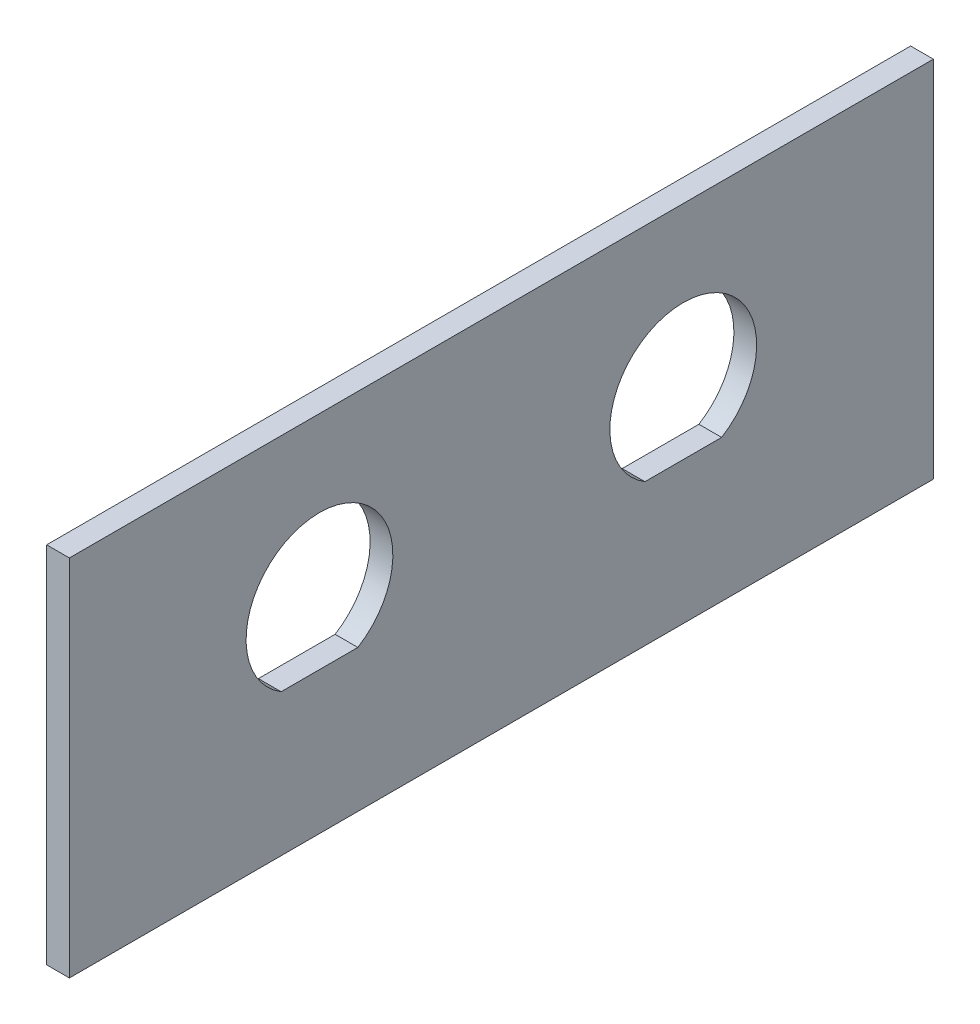
from build123d import *

# Parameters (mm, degrees)
SKETCH1_W           = 203.2
SKETCH1_H           = 120.65
BOSS_EXTRUDE1_DEPTH = 50.8
SKETCH2_W           = 196.85
SKETCH2_H           = 114.3
CUT_EXTRUDE1_DEPTH  = 51.8
SKETCH4_W           = 203.2
SKETCH4_H           = 120.65
SKETCH4_W_2         = 196.85
SKETCH4_H_2         = 114.3
BOSS_EXTRUDE2_DEPTH = 6.35
CUT_EXTRUDE5_DEPTH  = 121.65
CUT_EXTRUDE6_REACH  = 205.2
CUT_EXTRUDE7_REACH  = 205.2
SKETCH13_R          = 12.55395
SKETCH14_W          = 200.025
SKETCH14_H          = 120.65
CUT_EXTRUDE8_DEPTH  = 51.8


with BuildPart() as part:
    # Sketch1 → Boss-Extrude1 (new body)
    with BuildSketch(Plane(origin=(0, 0, 0), x_dir=(1, 0, 0), z_dir=(0, 1, 0))):
        Rectangle(SKETCH1_W, SKETCH1_H)
    extrude(amount=BOSS_EXTRUDE1_DEPTH)

    # Sketch2 → Cut-Extrude1 (cut, through all)
    with BuildSketch(Plane(origin=(0, 50.8, 0), x_dir=(1, 0, 0), z_dir=(0, 1, 0))):
        Rectangle(SKETCH2_W, SKETCH2_H)
    extrude(amount=-CUT_EXTRUDE1_DEPTH, mode=Mode.SUBTRACT)

    # Sketch4 → Boss-Extrude2 (add)
    with BuildSketch(Plane(origin=(0, 50.8, 0), x_dir=(1, 0, 0), z_dir=(0, 1, 0))):
        Rectangle(SKETCH4_W, SKETCH4_H)
        Rectangle(SKETCH4_W_2, SKETCH4_H_2, mode=Mode.SUBTRACT)
    extrude(amount=-BOSS_EXTRUDE2_DEPTH)

    # Sketch10 → Cut-Extrude5 (cut, through all)
    with BuildSketch(Plane.XY.offset(60.325)):
        with BuildLine():
            ThreePointArc((-65.9511, 22.225), (-81.206975571, 31.167602912), (-81.556705839, 13.4874))
            Line((-81.556705839, 13.4874), (-70.843294161, 13.4874))
            ThreePointArc((-70.843294161, 13.4874), (-67.257397088, 17.218024429), (-65.9511, 22.225))
        make_face()
        with BuildLine():
            ThreePointArc((-15.1511, 22.225), (-30.406975571, 31.167602912), (-30.756705839, 13.4874))
            Line((-30.756705839, 13.4874), (-20.043294161, 13.4874))
            ThreePointArc((-20.043294161, 13.4874), (-16.457397088, 17.218024429), (-15.1511, 22.225))
        make_face()
        with BuildLine():
            ThreePointArc((35.6489, 22.225), (20.393024429, 31.167602912), (20.043294161, 13.4874))
            Line((20.043294161, 13.4874), (30.756705839, 13.4874))
            ThreePointArc((30.756705839, 13.4874), (34.342602912, 17.218024429), (35.6489, 22.225))
        make_face()
        with BuildLine():
            Line((70.843294161, 13.4874), (81.556705839, 13.4874))
            ThreePointArc((81.556705839, 13.4874), (85.142602912, 17.218024429), (86.4489, 22.225))
            ThreePointArc((86.4489, 22.225), (71.193024429, 31.167602912), (70.843294161, 13.4874))
        make_face()
    extrude(amount=-CUT_EXTRUDE5_DEPTH, mode=Mode.SUBTRACT)

    # Sketch12 → Cut-Extrude6 (cut, up to next)
    with BuildSketch(Plane(origin=(101.6, 0, 0), x_dir=(0, 0, -1), z_dir=(1, 0, 0)), mode=Mode.PRIVATE) as cut_extrude6_sk1:
        with BuildLine():
            ThreePointArc((-20.043294161, 19.8374), (-25.4, 38.8239), (-30.756705839, 19.8374))
            Line((-30.756705839, 19.8374), (-20.043294161, 19.8374))
        make_face()
    cut_extrude6_tool1 = extrude(cut_extrude6_sk1.sketch, amount=-CUT_EXTRUDE6_REACH, mode=Mode.PRIVATE) & part.part
    add(cut_extrude6_tool1.solids().sort_by_distance((101.6, 28.896198, 25.4))[0], mode=Mode.SUBTRACT)
    # Sketch12 → Cut-Extrude6 (cut, up to next)
    with BuildSketch(Plane(origin=(101.6, 0, 0), x_dir=(0, 0, -1), z_dir=(1, 0, 0)), mode=Mode.PRIVATE) as cut_extrude6_sk2:
        with BuildLine():
            ThreePointArc((30.756705839, 19.8374), (25.4, 38.8239), (20.043294161, 19.8374))
            Line((20.043294161, 19.8374), (30.756705839, 19.8374))
        make_face()
    cut_extrude6_tool2 = extrude(cut_extrude6_sk2.sketch, amount=-CUT_EXTRUDE6_REACH, mode=Mode.PRIVATE) & part.part
    add(cut_extrude6_tool2.solids().sort_by_distance((101.6, 28.896198, -25.4))[0], mode=Mode.SUBTRACT)

    # Sketch13 → Cut-Extrude7 (cut, up to next)
    with BuildSketch(Plane.ZY.offset(101.6), mode=Mode.PRIVATE) as cut_extrude7_sk1:
        with Locations((15.875, 28.575)):
            Circle(SKETCH13_R)
    cut_extrude7_tool1 = extrude(cut_extrude7_sk1.sketch, amount=-CUT_EXTRUDE7_REACH, mode=Mode.PRIVATE) & part.part
    add(cut_extrude7_tool1.solids().sort_by_distance((-101.6, 28.575, 15.875))[0], mode=Mode.SUBTRACT)

    # Sketch14 → Cut-Extrude8 (cut, through all)
    with BuildSketch(Plane(origin=(0, 50.8, 0), x_dir=(1, 0, 0), z_dir=(0, 1, 0))):
        with Locations((-1.5875, 0)):
            Rectangle(SKETCH14_W, SKETCH14_H)
    extrude(amount=-CUT_EXTRUDE8_DEPTH, mode=Mode.SUBTRACT)


solid = part.part
